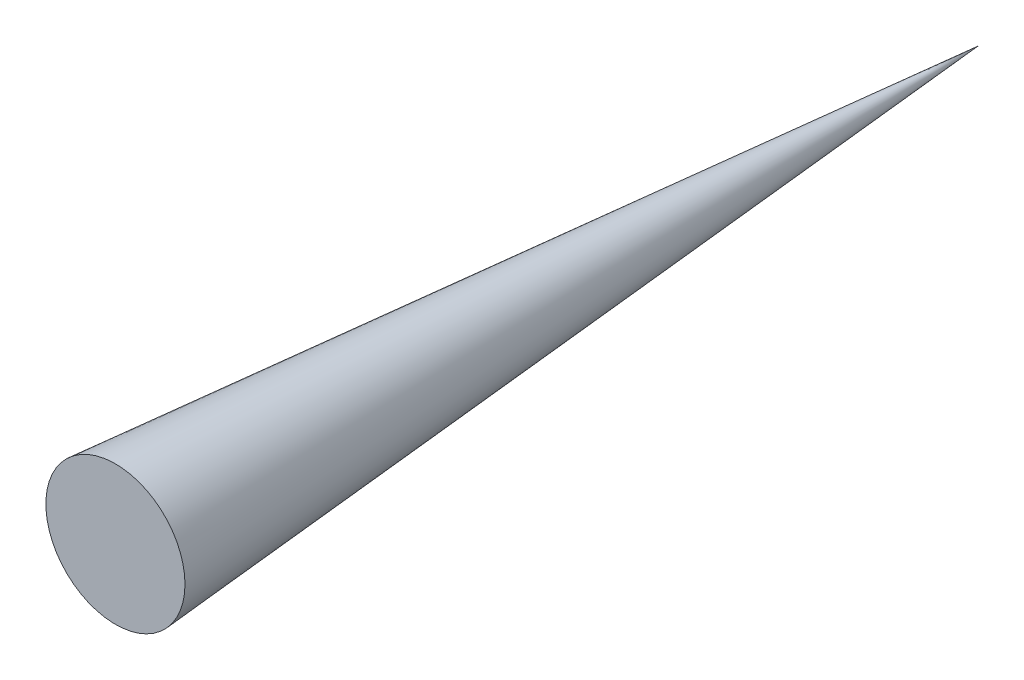
from build123d import *


with BuildPart() as part:
    # Sketch1 → Revolve1 (revolve)
    with BuildSketch(Plane(origin=(0, 0, 0), x_dir=(1, 0, 0), z_dir=(0, 1, 0))):
        Polygon((0, 0), (-30, 0), (0, 372), align=None)
    revolve(axis=Axis((0, 0, 33.992998997), (0, 0, -1)))


solid = part.part
